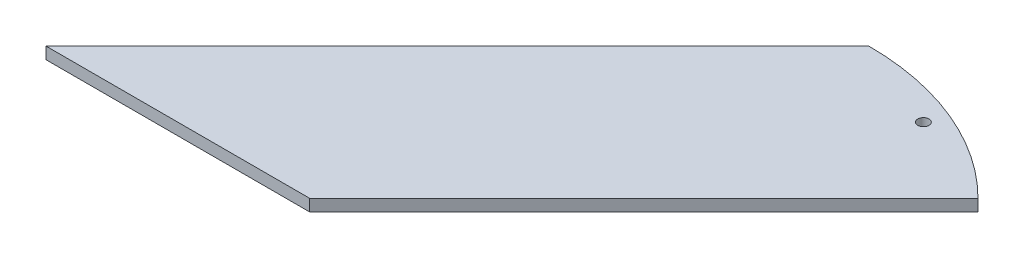
from build123d import *

# Parameters (mm, degrees)
SKETCH1_R           = 1.5
BOSS_EXTRUDE1_DEPTH = 3.175


with BuildPart() as part:
    # Sketch1 → Boss-Extrude1 (new body)
    with BuildSketch(Plane(origin=(0, 0, 0), x_dir=(1, 0, 0), z_dir=(0, 1, 0))):
        with BuildLine():
            ThreePointArc((-25, 35.355339059), (2.059805007, 29.972809184), (25, 14.644660941))
            Line((25, 14.644660941), (-64.644660941, -75))
            Line((-64.644660941, -75), (-135.355339059, -75))
            Line((-135.355339059, -75), (-25, 35.355339059))
        make_face()
        with Locations((0, 25)):
            Circle(SKETCH1_R, mode=Mode.SUBTRACT)
    extrude(amount=BOSS_EXTRUDE1_DEPTH)


solid = part.part
